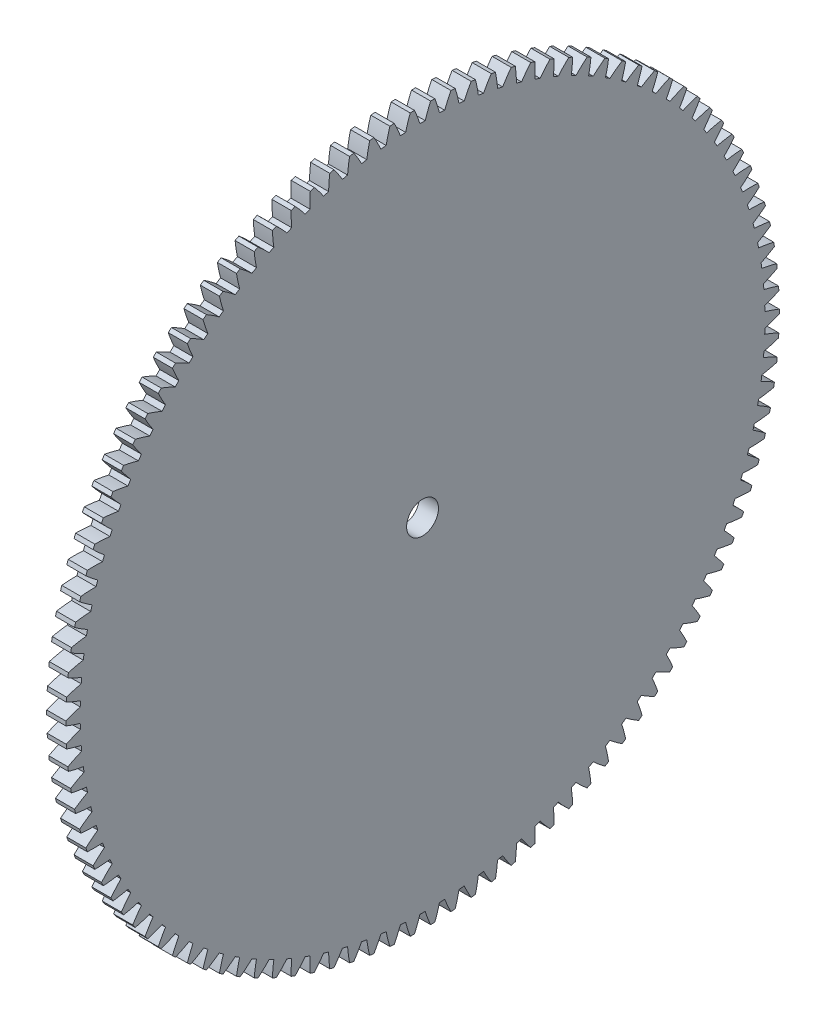
from build123d import *

# Parameters (mm, degrees)
BASPROSKE_W     = 3
BASPROSKE_H     = 56
TOOTHCUT_DEPTH  = 80.252760204
TEETHCUTS_COUNT = 110
TEETHCUTS_ANGLE = 356.727272727
BORSKE_R        = 2.5
BORE_DEPTH      = 50.0000508


with BuildPart() as part:
    # BasProSke → Base-Revolve (revolve)
    with BuildSketch(Plane(origin=(0, 0, 0), x_dir=(1, 0, 0), z_dir=(0, 1, 0)), mode=Mode.PRIVATE) as base_revolve_sk:
        with Locations((1.5, 28)):
            Rectangle(BASPROSKE_W, BASPROSKE_H)
    revolve(base_revolve_sk.sketch.rotate(Axis((-10, 0, 0), (1, 0, 0)), 180), axis=Axis((-10, 0, 0), (1, 0, 0)))

    # TooCutSke → ToothCut (cut, through all)
    with BuildSketch(Plane(origin=(0, 0, 0), x_dir=(0, 0, -1), z_dir=(1, 0, 0))):
        with BuildLine():
            ThreePointArc((0.412521818, 53.747416931), (0, 53.749), (-0.412521818, 53.747416931))
            ThreePointArc((-0.412521818, 53.747416931), (-0.812571894, 54.891032439), (-1.274971795, 56.010890835))
            ThreePointArc((-1.274971795, 56.010890835), (0, 56.0254), (1.274971795, 56.010890835))
            ThreePointArc((1.274971795, 56.010890835), (0.812571894, 54.891032439), (0.412521818, 53.747416931))
        make_face()
    toothcut = extrude(amount=TOOTHCUT_DEPTH, mode=Mode.SUBTRACT)

    # TeethCuts: ToothCut ×110 about axis
    teethcuts_axis = Axis((-10, 0, 0), (1, 0, 0))
    for i in range(1, TEETHCUTS_COUNT):
        add(toothcut.rotate(teethcuts_axis, i * TEETHCUTS_ANGLE / (TEETHCUTS_COUNT - 1)), mode=Mode.SUBTRACT)

    # BorSke → Bore (cut, symmetric)
    with BuildSketch(Plane(origin=(0, 0, 0), x_dir=(0, 0, -1), z_dir=(1, 0, 0))):
        with Locations(Location((0, 0, 0), (0, 0, 180))):
            Circle(BORSKE_R)
    extrude(amount=BORE_DEPTH, both=True, mode=Mode.SUBTRACT)


solid = part.part
